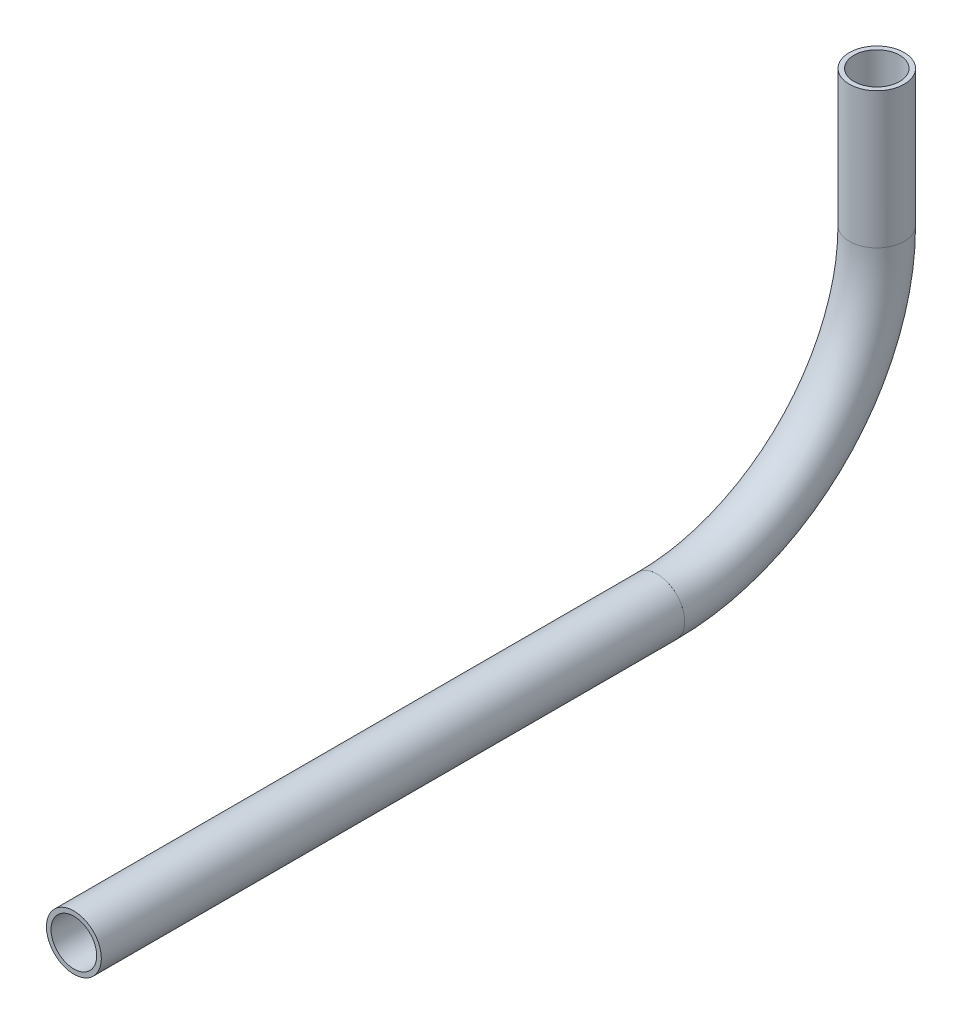
from build123d import *

# Parameters (mm, degrees)
SKETCH11_R                = 6.35
SKETCH11_R_2              = 5.2832
PIPE_0_5_SCH_40_1_DEPTH   = 134.99101558
SKETCH11_ON_SEGMENT_2_R   = 6.35
SKETCH11_ON_SEGMENT_2_R_2 = 5.2832
PIPE_0_5_SCH_40_1_2_ANGLE = 90
SKETCH11_ON_SEGMENT_3_R   = 6.35
SKETCH11_ON_SEGMENT_3_R_2 = 5.2832
PIPE_0_5_SCH_40_1_3_DEPTH = 31.49304163


with BuildPart() as part:
    # Sketch11 → Pipe 0.5 SCH 40(1) (new body)
    with BuildSketch(Plane(origin=(0, 670.165576631, 303.164595711), x_dir=(0, 1, 0), z_dir=(0, 0, -1))):
        Circle(SKETCH11_R)
        Circle(SKETCH11_R_2, mode=Mode.SUBTRACT)
    extrude(amount=PIPE_0_5_SCH_40_1_DEPTH)


with BuildPart() as body_2:
    # Sketch11 on segment 2 (carried to the start of arc 2) → Pipe 0.5 SCH 40_1 2 (revolve)
    with BuildSketch(Plane(origin=(0, 670.165576631, 168.173580131), x_dir=(0, 1, 0), z_dir=(0, 0, -1))):
        Circle(SKETCH11_ON_SEGMENT_2_R)
        Circle(SKETCH11_ON_SEGMENT_2_R_2, mode=Mode.SUBTRACT)
    revolve(axis=Axis((0, 720.965576631, 168.173580131), (1, 0, 0)), revolution_arc=PIPE_0_5_SCH_40_1_2_ANGLE)


with BuildPart() as body_3:
    # Sketch11 on segment 3 (carried to segment 3) → Pipe 0.5 SCH 40_1 3 (new body)
    with BuildSketch(Plane(origin=(0, 720.965576631, 117.373580131), x_dir=(0, 0, 1), z_dir=(0, 1, 0))):
        Circle(SKETCH11_ON_SEGMENT_3_R)
        Circle(SKETCH11_ON_SEGMENT_3_R_2, mode=Mode.SUBTRACT)
    extrude(amount=PIPE_0_5_SCH_40_1_3_DEPTH)


solid = Compound([part.part, body_2.part, body_3.part])
